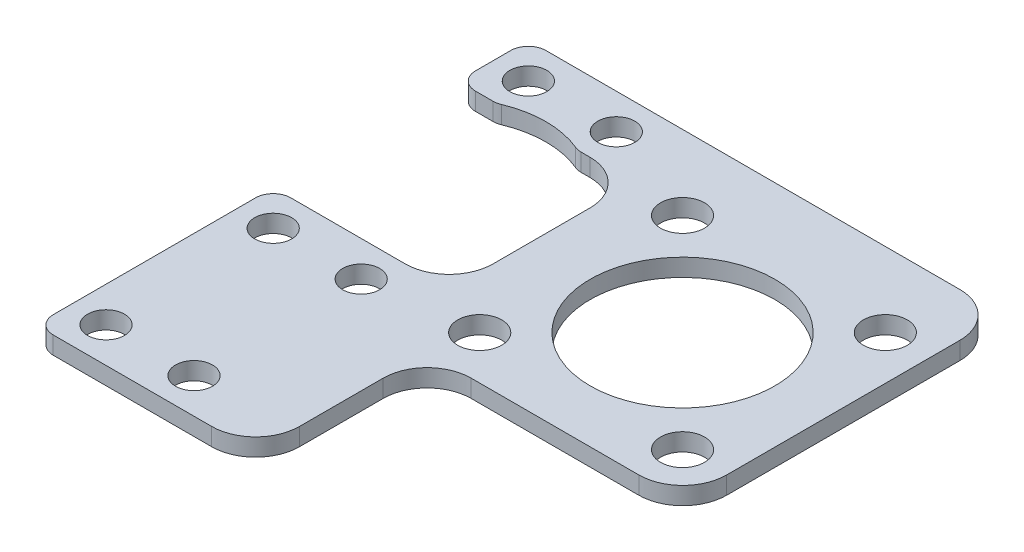
from build123d import *

# Parameters (mm, degrees)
SKETCH1_R           = 2.5
SKETCH1_R_2         = 2.1
SKETCH1_R_3         = 10.5
BOSS_EXTRUDE1_DEPTH = 2


with BuildPart() as part:
    # Sketch1 → Boss-Extrude1 (new body)
    with BuildSketch(Plane(origin=(0, 0, 0), x_dir=(1, 0, 0), z_dir=(0, 1, 0))):
        with BuildLine():
            Line((-35.525840533, 12), (-33.525840533, 12))
            ThreePointArc((-33.525840533, 12), (-33.133608263, 12.038838649), (-32.756609764, 12.153846154))
            ThreePointArc((-32.756609764, 12.153846154), (-28.525840533, 13), (-24.295071303, 12.153846154))
            ThreePointArc((-24.295071303, 12.153846154), (-23.918072804, 12.038838649), (-23.525840533, 12))
            Line((-23.525840533, 12), (-22.525840533, 12))
            ThreePointArc((-22.525840533, 12), (-18.990306627, 10.535533906), (-17.525840533, 7))
            Line((-17.525840533, 7), (-17.525840533, -4))
            ThreePointArc((-17.525840533, -4), (-18.990306627, -7.535533906), (-22.525840533, -9))
            Line((-22.525840533, -9), (-35.525840533, -9))
            ThreePointArc((-35.525840533, -9), (-36.940054096, -9.585786438), (-37.525840533, -11))
            Line((-37.525840533, -11), (-37.525840533, -34))
            ThreePointArc((-37.525840533, -34), (-36.940054096, -35.414213562), (-35.525840533, -36))
            Line((-35.525840533, -36), (-17.525840533, -36))
            ThreePointArc((-17.525840533, -36), (-13.990306627, -34.535533906), (-12.525840533, -31))
            Line((-12.525840533, -31), (-12.525840533, -21.5))
            ThreePointArc((-12.525840533, -21.5), (-11.061374439, -17.964466094), (-7.525840533, -16.5))
            Line((-7.525840533, -16.5), (11.525840533, -16.5))
            ThreePointArc((11.525840533, -16.5), (15.061374439, -15.035533906), (16.525840533, -11.5))
            Line((16.525840533, -11.5), (16.525840533, 15))
            ThreePointArc((16.525840533, 15), (15.061374439, 18.535533906), (11.525840533, 20))
            Line((11.525840533, 20), (-35.525840533, 20))
            ThreePointArc((-35.525840533, 20), (-36.940054096, 19.414213562), (-37.525840533, 18))
            Line((-37.525840533, 18), (-37.525840533, 14))
            ThreePointArc((-37.525840533, 14), (-36.940054096, 12.585786438), (-35.525840533, 12))
        make_face()
        with Locations((-11.525840533, 11.525840533)):
            Circle(SKETCH1_R, mode=Mode.SUBTRACT)
        with Locations((11.525840533, 11.525840533)):
            Circle(SKETCH1_R, mode=Mode.SUBTRACT)
        with Locations((11.525840533, -11.525840533)):
            Circle(SKETCH1_R, mode=Mode.SUBTRACT)
        with Locations((-11.525840533, -11.525840533)):
            Circle(SKETCH1_R, mode=Mode.SUBTRACT)
        with Locations((-33.525840533, 16)):
            Circle(SKETCH1_R_2, mode=Mode.SUBTRACT)
        with Locations((-23.525840533, 16)):
            Circle(SKETCH1_R_2, mode=Mode.SUBTRACT)
        with Locations((-33.525840533, -32)):
            Circle(SKETCH1_R_2, mode=Mode.SUBTRACT)
        with Locations((-23.525840533, -32)):
            Circle(SKETCH1_R_2, mode=Mode.SUBTRACT)
        with Locations((-33.525840533, -13)):
            Circle(SKETCH1_R_2, mode=Mode.SUBTRACT)
        with Locations((-23.525840533, -13)):
            Circle(SKETCH1_R_2, mode=Mode.SUBTRACT)
        Circle(SKETCH1_R_3, mode=Mode.SUBTRACT)
    extrude(amount=BOSS_EXTRUDE1_DEPTH)


solid = part.part
